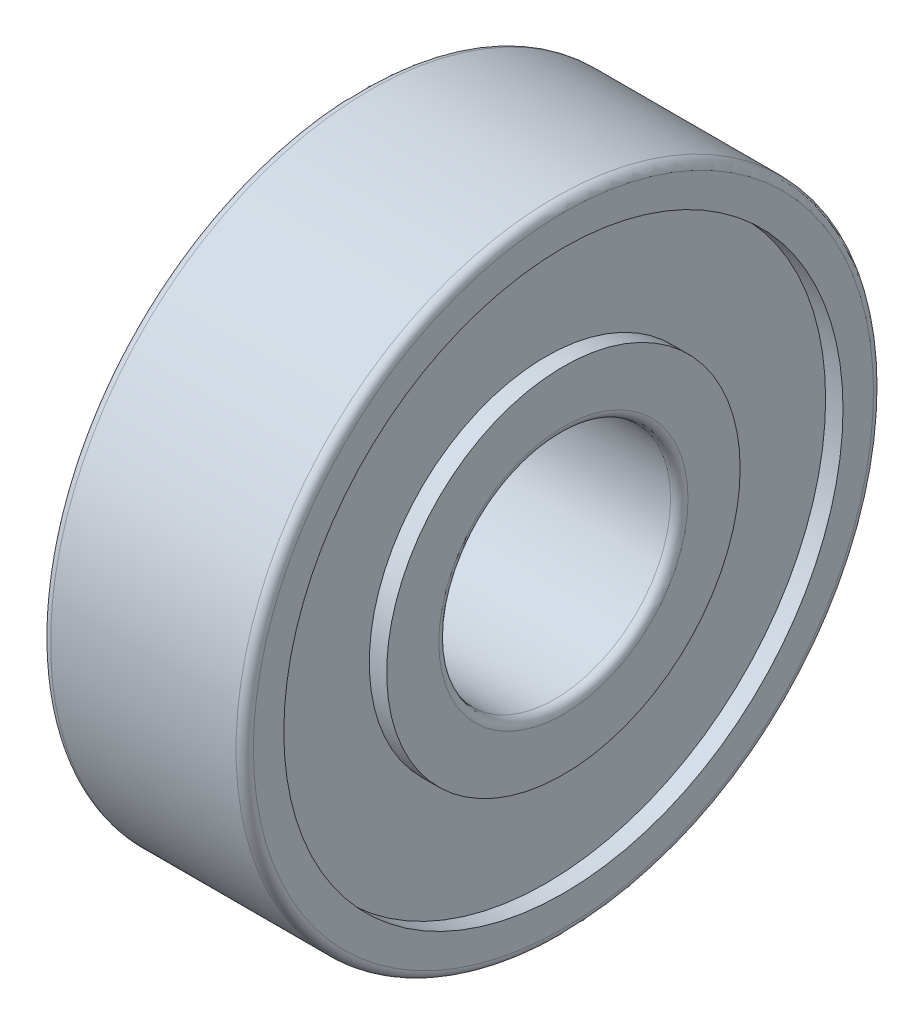
from build123d import *


with BuildPart() as part:
    # Sketch1 → Revolve1 (revolve)
    with BuildSketch(Plane.XY):
        with BuildLine():
            Line((0.3, 4), (6.7, 4))
            ThreePointArc((6.7, 4), (6.912132034, 4.087867966), (7, 4.3))
            Line((7, 4.3), (7, 6.1))
            Line((7, 6.1), (6.4, 6.1))
            Line((6.4, 6.1), (6.4, 9.65))
            Line((6.4, 9.65), (7, 9.65))
            Line((7, 9.65), (7, 10.7))
            ThreePointArc((7, 10.7), (6.912132034, 10.912132034), (6.7, 11))
            Line((6.7, 11), (0.3, 11))
            ThreePointArc((0.3, 11), (0.087867966, 10.912132034), (0, 10.7))
            Line((0, 10.7), (0, 9.65))
            Line((0, 9.65), (0.6, 9.65))
            Line((0.6, 9.65), (0.6, 6.1))
            Line((0.6, 6.1), (0, 6.1))
            Line((0, 6.1), (0, 4.3))
            ThreePointArc((0, 4.3), (0.087867966, 4.087867966), (0.3, 4))
        make_face()
    revolve(axis=Axis((-0.002803158, 0, 0), (1, 0, 0)))


solid = part.part
